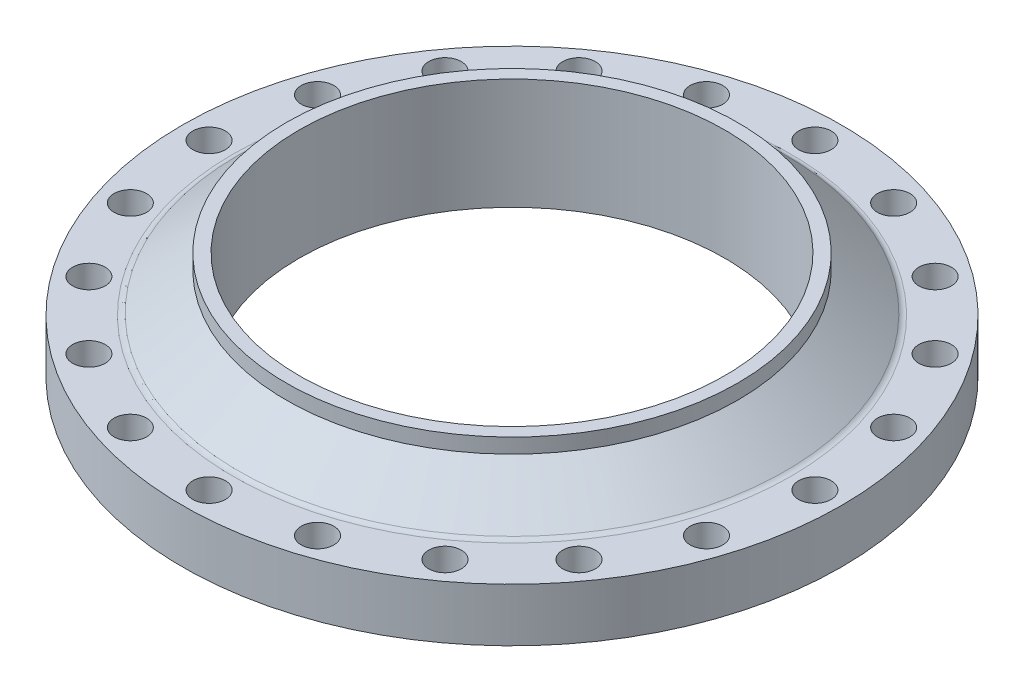
from build123d import *

# Parameters (mm, degrees)
CUT_EXTRUDE2_REACH = 147
SKETCH2_R          = 22


with BuildPart() as part:
    # Sketch1 → Revolve1 (revolve)
    with BuildSketch(Plane.XY):
        with BuildLine():
            Line((287.4, 150), (304.8, 150))
            Line((304.8, 150), (304.8, 130))
            Line((304.8, 130), (369.380900162, 79.543870957))
            ThreePointArc((369.380900162, 79.543870957), (372.862020012, 77.653777093), (376.768837866, 77))
            Line((376.768837866, 77), (445, 77))
            Line((445, 77), (445, 5))
            Line((445, 5), (375, 5))
            Line((375, 5), (370, 0))
            Line((370, 0), (287.4, 0))
            Line((287.4, 0), (287.4, 150))
        make_face()
    revolve(axis=Axis((0, 150, 0), (0, -1, 0)))

    # Sketch2 → Cut-Extrude2 (cut, up to next)
    with BuildSketch(Plane.XZ.offset(-5), mode=Mode.PRIVATE) as cut_extrude2_sk1:
        with Locations((0, 409)):
            Circle(SKETCH2_R)
    cut_extrude2_tool1 = extrude(cut_extrude2_sk1.sketch, amount=-CUT_EXTRUDE2_REACH, mode=Mode.PRIVATE) & part.part
    add(cut_extrude2_tool1.solids().sort_by_distance((0, 5, 409))[0], mode=Mode.SUBTRACT)
    # Sketch2 → Cut-Extrude2 (cut, up to next)
    with BuildSketch(Plane.XZ.offset(-5), mode=Mode.PRIVATE) as cut_extrude2_sk2:
        with Locations((126.387950699, 388.982115165)):
            Circle(SKETCH2_R)
    cut_extrude2_tool2 = extrude(cut_extrude2_sk2.sketch, amount=-CUT_EXTRUDE2_REACH, mode=Mode.PRIVATE) & part.part
    add(cut_extrude2_tool2.solids().sort_by_distance((126.387951, 5, 388.982115))[0], mode=Mode.SUBTRACT)
    # Sketch2 → Cut-Extrude2 (cut, up to next)
    with BuildSketch(Plane.XZ.offset(-5), mode=Mode.PRIVATE) as cut_extrude2_sk3:
        with Locations((240.404168188, 330.887950699)):
            Circle(SKETCH2_R)
    cut_extrude2_tool3 = extrude(cut_extrude2_sk3.sketch, amount=-CUT_EXTRUDE2_REACH, mode=Mode.PRIVATE) & part.part
    add(cut_extrude2_tool3.solids().sort_by_distance((240.404168, 5, 330.887951))[0], mode=Mode.SUBTRACT)
    # Sketch2 → Cut-Extrude2 (cut, up to next)
    with BuildSketch(Plane.XZ.offset(-5), mode=Mode.PRIVATE) as cut_extrude2_sk4:
        with Locations((330.887950699, 240.404168188)):
            Circle(SKETCH2_R)
    cut_extrude2_tool4 = extrude(cut_extrude2_sk4.sketch, amount=-CUT_EXTRUDE2_REACH, mode=Mode.PRIVATE) & part.part
    add(cut_extrude2_tool4.solids().sort_by_distance((330.887951, 5, 240.404168))[0], mode=Mode.SUBTRACT)
    # Sketch2 → Cut-Extrude2 (cut, up to next)
    with BuildSketch(Plane.XZ.offset(-5), mode=Mode.PRIVATE) as cut_extrude2_sk5:
        with Locations((388.982115165, 126.387950699)):
            Circle(SKETCH2_R)
    cut_extrude2_tool5 = extrude(cut_extrude2_sk5.sketch, amount=-CUT_EXTRUDE2_REACH, mode=Mode.PRIVATE) & part.part
    add(cut_extrude2_tool5.solids().sort_by_distance((388.982115, 5, 126.387951))[0], mode=Mode.SUBTRACT)
    # Sketch2 → Cut-Extrude2 (cut, up to next)
    with BuildSketch(Plane.XZ.offset(-5), mode=Mode.PRIVATE) as cut_extrude2_sk6:
        with Locations((409, 0)):
            Circle(SKETCH2_R)
    cut_extrude2_tool6 = extrude(cut_extrude2_sk6.sketch, amount=-CUT_EXTRUDE2_REACH, mode=Mode.PRIVATE) & part.part
    add(cut_extrude2_tool6.solids().sort_by_distance((409, 5, 0))[0], mode=Mode.SUBTRACT)
    # Sketch2 → Cut-Extrude2 (cut, up to next)
    with BuildSketch(Plane.XZ.offset(-5), mode=Mode.PRIVATE) as cut_extrude2_sk7:
        with Locations((388.982115165, -126.387950699)):
            Circle(SKETCH2_R)
    cut_extrude2_tool7 = extrude(cut_extrude2_sk7.sketch, amount=-CUT_EXTRUDE2_REACH, mode=Mode.PRIVATE) & part.part
    add(cut_extrude2_tool7.solids().sort_by_distance((388.982115, 5, -126.387951))[0], mode=Mode.SUBTRACT)
    # Sketch2 → Cut-Extrude2 (cut, up to next)
    with BuildSketch(Plane.XZ.offset(-5), mode=Mode.PRIVATE) as cut_extrude2_sk8:
        with Locations((330.887950699, -240.404168188)):
            Circle(SKETCH2_R)
    cut_extrude2_tool8 = extrude(cut_extrude2_sk8.sketch, amount=-CUT_EXTRUDE2_REACH, mode=Mode.PRIVATE) & part.part
    add(cut_extrude2_tool8.solids().sort_by_distance((330.887951, 5, -240.404168))[0], mode=Mode.SUBTRACT)
    # Sketch2 → Cut-Extrude2 (cut, up to next)
    with BuildSketch(Plane.XZ.offset(-5), mode=Mode.PRIVATE) as cut_extrude2_sk9:
        with Locations((240.404168188, -330.887950699)):
            Circle(SKETCH2_R)
    cut_extrude2_tool9 = extrude(cut_extrude2_sk9.sketch, amount=-CUT_EXTRUDE2_REACH, mode=Mode.PRIVATE) & part.part
    add(cut_extrude2_tool9.solids().sort_by_distance((240.404168, 5, -330.887951))[0], mode=Mode.SUBTRACT)
    # Sketch2 → Cut-Extrude2 (cut, up to next)
    with BuildSketch(Plane.XZ.offset(-5), mode=Mode.PRIVATE) as cut_extrude2_sk10:
        with Locations((126.387950699, -388.982115165)):
            Circle(SKETCH2_R)
    cut_extrude2_tool10 = extrude(cut_extrude2_sk10.sketch, amount=-CUT_EXTRUDE2_REACH, mode=Mode.PRIVATE) & part.part
    add(cut_extrude2_tool10.solids().sort_by_distance((126.387951, 5, -388.982115))[0], mode=Mode.SUBTRACT)
    # Sketch2 → Cut-Extrude2 (cut, up to next)
    with BuildSketch(Plane.XZ.offset(-5), mode=Mode.PRIVATE) as cut_extrude2_sk11:
        with Locations((0, -409)):
            Circle(SKETCH2_R)
    cut_extrude2_tool11 = extrude(cut_extrude2_sk11.sketch, amount=-CUT_EXTRUDE2_REACH, mode=Mode.PRIVATE) & part.part
    add(cut_extrude2_tool11.solids().sort_by_distance((0, 5, -409))[0], mode=Mode.SUBTRACT)
    # Sketch2 → Cut-Extrude2 (cut, up to next)
    with BuildSketch(Plane.XZ.offset(-5), mode=Mode.PRIVATE) as cut_extrude2_sk12:
        with Locations((-126.387950699, -388.982115165)):
            Circle(SKETCH2_R)
    cut_extrude2_tool12 = extrude(cut_extrude2_sk12.sketch, amount=-CUT_EXTRUDE2_REACH, mode=Mode.PRIVATE) & part.part
    add(cut_extrude2_tool12.solids().sort_by_distance((-126.387951, 5, -388.982115))[0], mode=Mode.SUBTRACT)
    # Sketch2 → Cut-Extrude2 (cut, up to next)
    with BuildSketch(Plane.XZ.offset(-5), mode=Mode.PRIVATE) as cut_extrude2_sk13:
        with Locations((-240.404168188, -330.887950699)):
            Circle(SKETCH2_R)
    cut_extrude2_tool13 = extrude(cut_extrude2_sk13.sketch, amount=-CUT_EXTRUDE2_REACH, mode=Mode.PRIVATE) & part.part
    add(cut_extrude2_tool13.solids().sort_by_distance((-240.404168, 5, -330.887951))[0], mode=Mode.SUBTRACT)
    # Sketch2 → Cut-Extrude2 (cut, up to next)
    with BuildSketch(Plane.XZ.offset(-5), mode=Mode.PRIVATE) as cut_extrude2_sk14:
        with Locations((-330.887950699, -240.404168188)):
            Circle(SKETCH2_R)
    cut_extrude2_tool14 = extrude(cut_extrude2_sk14.sketch, amount=-CUT_EXTRUDE2_REACH, mode=Mode.PRIVATE) & part.part
    add(cut_extrude2_tool14.solids().sort_by_distance((-330.887951, 5, -240.404168))[0], mode=Mode.SUBTRACT)
    # Sketch2 → Cut-Extrude2 (cut, up to next)
    with BuildSketch(Plane.XZ.offset(-5), mode=Mode.PRIVATE) as cut_extrude2_sk15:
        with Locations((-388.982115165, -126.387950699)):
            Circle(SKETCH2_R)
    cut_extrude2_tool15 = extrude(cut_extrude2_sk15.sketch, amount=-CUT_EXTRUDE2_REACH, mode=Mode.PRIVATE) & part.part
    add(cut_extrude2_tool15.solids().sort_by_distance((-388.982115, 5, -126.387951))[0], mode=Mode.SUBTRACT)
    # Sketch2 → Cut-Extrude2 (cut, up to next)
    with BuildSketch(Plane.XZ.offset(-5), mode=Mode.PRIVATE) as cut_extrude2_sk16:
        with Locations((-409, 0)):
            Circle(SKETCH2_R)
    cut_extrude2_tool16 = extrude(cut_extrude2_sk16.sketch, amount=-CUT_EXTRUDE2_REACH, mode=Mode.PRIVATE) & part.part
    add(cut_extrude2_tool16.solids().sort_by_distance((-409, 5, 0))[0], mode=Mode.SUBTRACT)
    # Sketch2 → Cut-Extrude2 (cut, up to next)
    with BuildSketch(Plane.XZ.offset(-5), mode=Mode.PRIVATE) as cut_extrude2_sk17:
        with Locations((-388.982115165, 126.387950699)):
            Circle(SKETCH2_R)
    cut_extrude2_tool17 = extrude(cut_extrude2_sk17.sketch, amount=-CUT_EXTRUDE2_REACH, mode=Mode.PRIVATE) & part.part
    add(cut_extrude2_tool17.solids().sort_by_distance((-388.982115, 5, 126.387951))[0], mode=Mode.SUBTRACT)
    # Sketch2 → Cut-Extrude2 (cut, up to next)
    with BuildSketch(Plane.XZ.offset(-5), mode=Mode.PRIVATE) as cut_extrude2_sk18:
        with Locations((-330.887950699, 240.404168188)):
            Circle(SKETCH2_R)
    cut_extrude2_tool18 = extrude(cut_extrude2_sk18.sketch, amount=-CUT_EXTRUDE2_REACH, mode=Mode.PRIVATE) & part.part
    add(cut_extrude2_tool18.solids().sort_by_distance((-330.887951, 5, 240.404168))[0], mode=Mode.SUBTRACT)
    # Sketch2 → Cut-Extrude2 (cut, up to next)
    with BuildSketch(Plane.XZ.offset(-5), mode=Mode.PRIVATE) as cut_extrude2_sk19:
        with Locations((-240.404168188, 330.887950699)):
            Circle(SKETCH2_R)
    cut_extrude2_tool19 = extrude(cut_extrude2_sk19.sketch, amount=-CUT_EXTRUDE2_REACH, mode=Mode.PRIVATE) & part.part
    add(cut_extrude2_tool19.solids().sort_by_distance((-240.404168, 5, 330.887951))[0], mode=Mode.SUBTRACT)
    # Sketch2 → Cut-Extrude2 (cut, up to next)
    with BuildSketch(Plane.XZ.offset(-5), mode=Mode.PRIVATE) as cut_extrude2_sk20:
        with Locations((-126.387950699, 388.982115165)):
            Circle(SKETCH2_R)
    cut_extrude2_tool20 = extrude(cut_extrude2_sk20.sketch, amount=-CUT_EXTRUDE2_REACH, mode=Mode.PRIVATE) & part.part
    add(cut_extrude2_tool20.solids().sort_by_distance((-126.387951, 5, 388.982115))[0], mode=Mode.SUBTRACT)


solid = part.part
